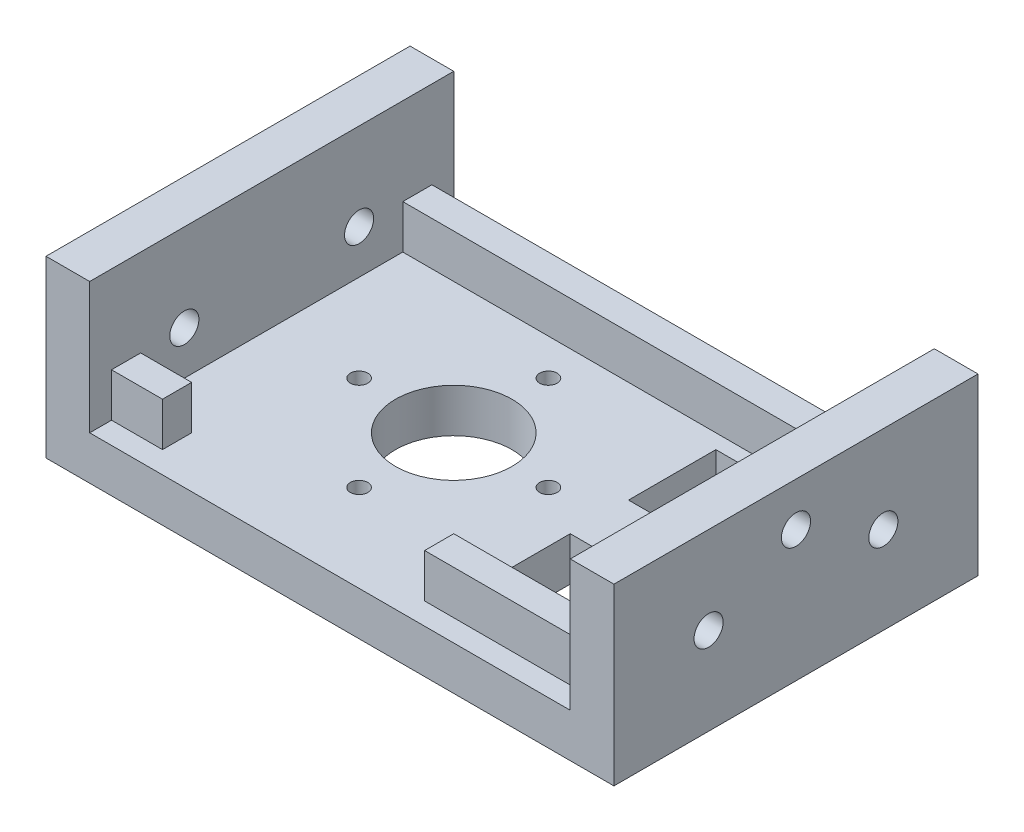
from build123d import *

# Parameters (mm, degrees)
CROQUIS1_W              = 39
CROQUIS1_H              = 25
CROQUIS1_R              = 4.000000275
CROQUIS1_R_2            = 0.600000034
CROQUIS1_W_2            = 8
CROQUIS1_H_2            = 6
SALIENTE_EXTRUIR1_DEPTH = 3
SALIENTE_EXTRUIR2_DEPTH = 3
CROQUIS3_W              = 3
CROQUIS3_H              = 25
SALIENTE_EXTRUIR3_DEPTH = 6
CROQUIS4_R              = 1
CORTAR_EXTRUIR1_DEPTH   = 45
CROQUIS5_R              = 1
CORTAR_EXTRUIR2_DEPTH   = 27


with BuildPart() as part:
    # Croquis1 → Saliente-Extruir1 (new body)
    with BuildSketch(Plane(origin=(0, 0, 0), x_dir=(1, 0, 0), z_dir=(0, 1, 0))):
        with Locations((0.907645754, 1.248012912)):
            Rectangle(CROQUIS1_W, CROQUIS1_H)
        with Locations((-3.09235459, 1.24801291)):
            Circle(CROQUIS1_R, mode=Mode.SUBTRACT)
        with Locations((-3.092354224, 7.748013103)):
            Circle(CROQUIS1_R_2, mode=Mode.SUBTRACT)
        with Locations((3.407645945, 1.248012891)):
            Circle(CROQUIS1_R_2, mode=Mode.SUBTRACT)
        with Locations((-3.092354267, -5.251987278)):
            Circle(CROQUIS1_R_2, mode=Mode.SUBTRACT)
        with Locations((-9.592354436, 1.248012934)):
            Circle(CROQUIS1_R_2, mode=Mode.SUBTRACT)
        with Locations((10.907645754, -3.751987088)):
            Rectangle(CROQUIS1_W_2, CROQUIS1_H_2, mode=Mode.SUBTRACT)
        with Locations((10.907645754, 6.248012912)):
            Rectangle(CROQUIS1_W_2, CROQUIS1_H_2, mode=Mode.SUBTRACT)
    extrude(amount=SALIENTE_EXTRUIR1_DEPTH)

    # Croquis2 → Saliente-Extruir2 (add)
    with BuildSketch(Plane(origin=(0, 3, 0), x_dir=(1, 0, 0), z_dir=(0, 1, 0))):
        Polygon((-18.592354246, 13.748012912), (-15.592354246, 13.748012912), (-15.592354246, 12.248012912), (17.407645754, 12.248012912), (17.407645754, 13.748012912), (20.407645754, 13.748012912), (20.407645754, -11.251987088), (17.407645754, -11.251987088), (17.407645754, -9.751987088), (5.907645754, -9.751987088), (5.907645754, -7.751987088), (17.407645754, -7.751987088), (17.407645754, 10.248012912), (-15.592354246, 10.248012912), (-15.592354246, -7.751987088), (-12.092354246, -7.751987088), (-12.092354246, -9.751987088), (-15.592354246, -9.751987088), (-15.592354246, -11.251987088), (-18.592354246, -11.251987088), align=None)
    extrude(amount=SALIENTE_EXTRUIR2_DEPTH)

    # Croquis3 → Saliente-Extruir3 (add)
    with BuildSketch(Plane(origin=(0, 6, 0), x_dir=(1, 0, 0), z_dir=(0, 1, 0))):
        with Locations((-17.092354246, 1.248012912)):
            Rectangle(CROQUIS3_W, CROQUIS3_H)
        with Locations((18.907645754, 1.248012912)):
            Rectangle(CROQUIS3_W, CROQUIS3_H)
    extrude(amount=SALIENTE_EXTRUIR3_DEPTH)

    # Croquis4 → Cortar-Extruir1 (cut)
    with BuildSketch(Plane.ZY.offset(18.592354246)):
        with Locations((-7.248012912, 6)):
            Circle(CROQUIS4_R)
        with Locations((4.751987088, 6)):
            Circle(CROQUIS4_R)
    extrude(amount=-CORTAR_EXTRUIR1_DEPTH, mode=Mode.SUBTRACT)

    # Croquis5 → Cortar-Extruir2 (cut)
    with BuildSketch(Plane(origin=(20.407645754, 0, 0), x_dir=(0, 0, -1), z_dir=(1, 0, 0))):
        with Locations((1.248012912, 9)):
            Circle(CROQUIS5_R)
    extrude(amount=-CORTAR_EXTRUIR2_DEPTH, mode=Mode.SUBTRACT)


solid = part.part
